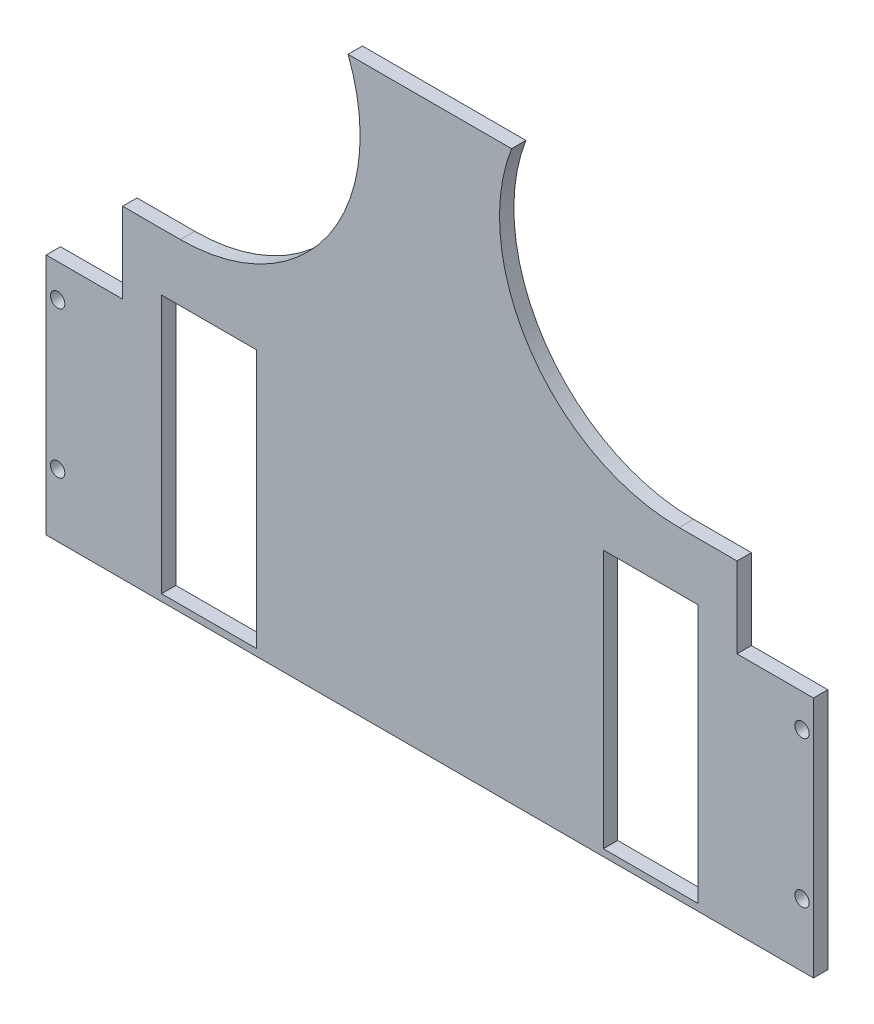
from build123d import *

# Parameters (mm, degrees)
SKETCH1_W           = 267
SKETCH1_H           = 267.4
SKETCH1_R           = 2.5
SKETCH1_W_2         = 33
SKETCH1_H_2         = 90
BOSS_EXTRUDE1_DEPTH = 5
SKETCH6_W           = 267
SKETCH6_H           = 70.024397165
CUT_EXTRUDE4_DEPTH  = 6


with BuildPart() as part:
    # Sketch1 → Boss-Extrude1 (new body)
    with BuildSketch(Plane.XY):
        with Locations((-3262.1, -202.7)):
            Rectangle(SKETCH1_W, SKETCH1_H)
        with Locations((-3132.6, -193.5)):
            Circle(SKETCH1_R, mode=Mode.SUBTRACT)
        with Locations((-3132.6, -244.5)):
            Circle(SKETCH1_R, mode=Mode.SUBTRACT)
        with Locations((-3391.6, -244.5)):
            Circle(SKETCH1_R, mode=Mode.SUBTRACT)
        with Locations((-3391.6, -193.5)):
            Circle(SKETCH1_R, mode=Mode.SUBTRACT)
        with Locations((-3185.24, -219)):
            Rectangle(SKETCH1_W_2, SKETCH1_H_2, mode=Mode.SUBTRACT)
        with Locations((-3338.96, -219)):
            Rectangle(SKETCH1_W_2, SKETCH1_H_2, mode=Mode.SUBTRACT)
    extrude(amount=BOSS_EXTRUDE1_DEPTH)

    # Sketch6 → Cut-Extrude4 (cut, through all)
    with BuildSketch(Plane.XY.offset(5)):
        with BuildLine():
            Line((-3233.659911457, -69), (-3128.6, -69))
            Line((-3128.6, -69), (-3128.6, -182))
            Line((-3128.6, -182), (-3155.204338358, -182))
            Line((-3155.204338358, -182), (-3155.204338358, -154))
            Line((-3155.204338358, -154), (-3175.350392508, -154))
            ThreePointArc((-3175.350392508, -154), (-3226.889212828, -126.855339059), (-3233.659911457, -69))
        make_face()
        with Locations((-3262.1, -301.387801417)):
            Rectangle(SKETCH6_W, SKETCH6_H)
        with BuildLine():
            Line((-3290.540088544, -69), (-3395.6, -69))
            Line((-3395.6, -69), (-3395.6, -182))
            Line((-3395.6, -182), (-3368.995661642, -182))
            Line((-3368.995661642, -182), (-3368.995661642, -154))
            Line((-3368.995661642, -154), (-3348.849607492, -154))
            ThreePointArc((-3348.849607492, -154), (-3297.310787172, -126.855339059), (-3290.540088544, -69))
        make_face()
    extrude(amount=-CUT_EXTRUDE4_DEPTH, mode=Mode.SUBTRACT)


solid = part.part
